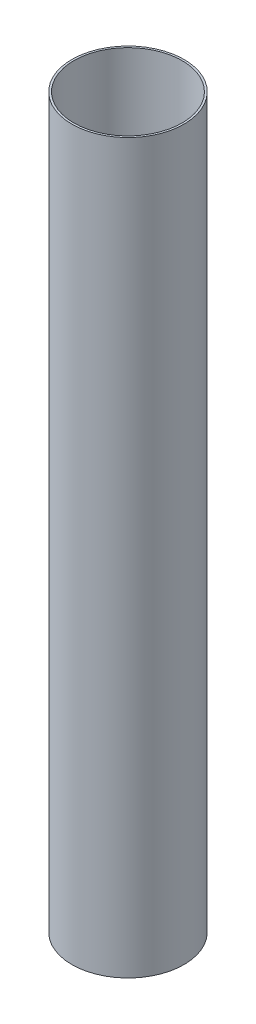
from build123d import *

# Parameters (mm, degrees)
SKETCH1_R           = 28.5
SKETCH1_R_2         = 27.5
BOSS_EXTRUDE1_DEPTH = 370


with BuildPart() as part:
    # Sketch1 → Boss-Extrude1 (new body)
    with BuildSketch(Plane(origin=(0, 0, 0), x_dir=(1, 0, 0), z_dir=(0, 1, 0))):
        Circle(SKETCH1_R)
        Circle(SKETCH1_R_2, mode=Mode.SUBTRACT)
    extrude(amount=BOSS_EXTRUDE1_DEPTH)


solid = part.part
